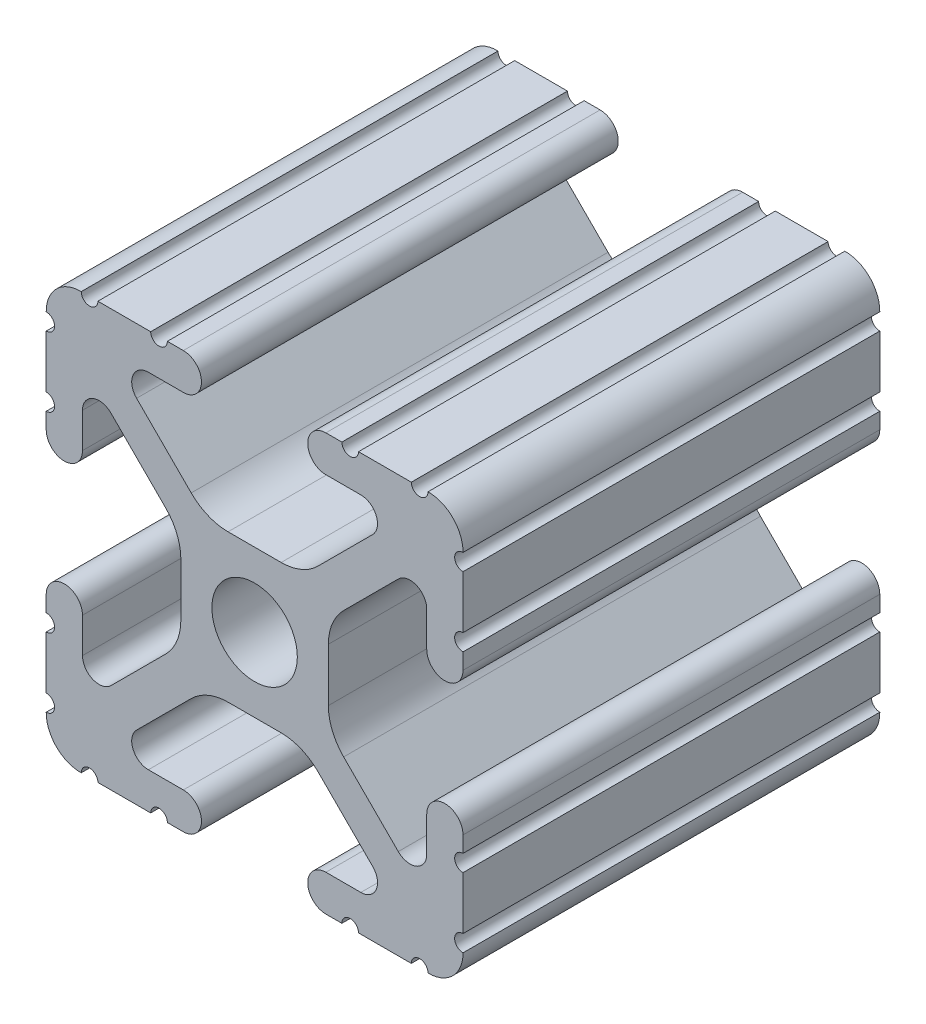
from build123d import *

# Parameters (mm, degrees)
SKETCH1_R           = 2.6035
BOSS_EXTRUDE1_DEPTH = 25.4


with BuildPart() as part:
    # Sketch1 → Boss-Extrude1 (new body)
    with BuildSketch(Plane(origin=(0, 0, -25.4), x_dir=(-1, 0, 0), z_dir=(0, 0, -1))):
        with BuildLine():
            Line((12.7, -9.5504), (12.7, -6.3330836))
            ThreePointArc((12.7, -6.3330836), (12.192, -5.8250836), (12.7, -5.3170836))
            Line((12.7, -5.3170836), (12.7, -4.3434))
            ThreePointArc((12.7, -4.3434), (11.5951, -3.2385), (10.4902, -4.3434))
            Line((10.4902, -4.3434), (10.4902, -6.474794456))
            ThreePointArc((10.4902, -6.474794456), (9.863006367, -7.413456061), (8.75577951, -7.193214945))
            Line((8.75577951, -7.193214945), (5.42573597, -3.863171405))
            ThreePointArc((5.42573597, -3.863171405), (4.737482484, -2.833127272), (4.4958, -1.618107374))
            Line((4.4958, -1.618107374), (4.4958, 1.618107374))
            ThreePointArc((4.4958, 1.618107374), (4.737482484, 2.833127272), (5.42573597, 3.863171405))
            Line((5.42573597, 3.863171405), (8.75577951, 7.193214945))
            ThreePointArc((8.75577951, 7.193214945), (9.863006367, 7.413456061), (10.4902, 6.474794456))
            Line((10.4902, 6.474794456), (10.4902, 4.343399971))
            ThreePointArc((10.4902, 4.343399971), (11.5951, 3.238499971), (12.7, 4.343399971))
            Line((12.7, 4.343399971), (12.7, 5.3170836))
            ThreePointArc((12.7, 5.3170836), (12.192, 5.8250836), (12.7, 6.3330836))
            Line((12.7, 6.3330836), (12.7, 9.5504))
            ThreePointArc((12.7, 9.5504), (12.192000006, 10.058323491), (12.699846982, 10.566399977))
            ThreePointArc((12.699846982, 10.566399977), (12.082522516, 12.082522516), (10.566399977, 12.699846982))
            ThreePointArc((10.566399977, 12.699846982), (10.058323491, 12.192000006), (9.5504, 12.7))
            Line((9.5504, 12.7), (6.3330836, 12.7))
            ThreePointArc((6.3330836, 12.7), (5.8250836, 12.192), (5.3170836, 12.7))
            Line((5.3170836, 12.7), (4.3434, 12.7))
            ThreePointArc((4.3434, 12.7), (3.2385, 11.5951), (4.3434, 10.4902))
            Line((4.3434, 10.4902), (6.474794456, 10.4902))
            ThreePointArc((6.474794456, 10.4902), (7.413456061, 9.863006367), (7.193214945, 8.75577951))
            Line((7.193214945, 8.75577951), (3.863171405, 5.42573597))
            ThreePointArc((3.863171405, 5.42573597), (2.833127272, 4.737482484), (1.618107374, 4.4958))
            Line((1.618107374, 4.4958), (-1.618107374, 4.4958))
            ThreePointArc((-1.618107374, 4.4958), (-2.833127272, 4.737482484), (-3.863171405, 5.42573597))
            Line((-3.863171405, 5.42573597), (-7.193214945, 8.75577951))
            ThreePointArc((-7.193214945, 8.75577951), (-7.413456061, 9.863006367), (-6.474794456, 10.4902))
            Line((-6.474794456, 10.4902), (-4.343399971, 10.4902))
            ThreePointArc((-4.343399971, 10.4902), (-3.238499971, 11.5951), (-4.343399971, 12.7))
            Line((-4.343399971, 12.7), (-5.3170836, 12.7))
            ThreePointArc((-5.3170836, 12.7), (-5.8250836, 12.192), (-6.3330836, 12.7))
            Line((-6.3330836, 12.7), (-9.5504, 12.7))
            ThreePointArc((-9.5504, 12.7), (-10.058323491, 12.192000006), (-10.566399977, 12.699846982))
            ThreePointArc((-10.566399977, 12.699846982), (-12.082522516, 12.082522516), (-12.699846982, 10.566399977))
            ThreePointArc((-12.699846982, 10.566399977), (-12.192000006, 10.058323491), (-12.7, 9.5504))
            Line((-12.7, 9.5504), (-12.7, 6.3330836))
            ThreePointArc((-12.7, 6.3330836), (-12.192, 5.8250836), (-12.7, 5.3170836))
            Line((-12.7, 5.3170836), (-12.7, 4.3434))
            ThreePointArc((-12.7, 4.3434), (-11.5951, 3.2385), (-10.4902, 4.3434))
            Line((-10.4902, 4.3434), (-10.4902, 6.474794456))
            ThreePointArc((-10.4902, 6.474794456), (-9.863006367, 7.413456061), (-8.75577951, 7.193214945))
            Line((-8.75577951, 7.193214945), (-5.42573597, 3.863171405))
            ThreePointArc((-5.42573597, 3.863171405), (-4.737482484, 2.833127272), (-4.4958, 1.618107374))
            Line((-4.4958, 1.618107374), (-4.4958, -1.618107374))
            ThreePointArc((-4.4958, -1.618107374), (-4.737482484, -2.833127272), (-5.42573597, -3.863171405))
            Line((-5.42573597, -3.863171405), (-8.75577951, -7.193214945))
            ThreePointArc((-8.75577951, -7.193214945), (-9.863006367, -7.413456061), (-10.4902, -6.474794456))
            Line((-10.4902, -6.474794456), (-10.4902, -4.343399971))
            ThreePointArc((-10.4902, -4.343399971), (-11.5951, -3.238499971), (-12.7, -4.343399971))
            Line((-12.7, -4.343399971), (-12.7, -5.3170836))
            ThreePointArc((-12.7, -5.3170836), (-12.192, -5.8250836), (-12.7, -6.3330836))
            Line((-12.7, -6.3330836), (-12.7, -9.5504))
            ThreePointArc((-12.7, -9.5504), (-12.192000006, -10.058323491), (-12.699846982, -10.566399977))
            ThreePointArc((-12.699846982, -10.566399977), (-12.082522516, -12.082522516), (-10.566399977, -12.699846982))
            ThreePointArc((-10.566399977, -12.699846982), (-10.058323491, -12.192000006), (-9.5504, -12.7))
            Line((-9.5504, -12.7), (-6.3330836, -12.7))
            ThreePointArc((-6.3330836, -12.7), (-5.8250836, -12.192), (-5.3170836, -12.7))
            Line((-5.3170836, -12.7), (-4.3434, -12.7))
            ThreePointArc((-4.3434, -12.7), (-3.2385, -11.5951), (-4.3434, -10.4902))
            Line((-4.3434, -10.4902), (-6.474794456, -10.4902))
            ThreePointArc((-6.474794456, -10.4902), (-7.413456061, -9.863006367), (-7.193214945, -8.75577951))
            Line((-7.193214945, -8.75577951), (-3.863171405, -5.42573597))
            ThreePointArc((-3.863171405, -5.42573597), (-2.833127272, -4.737482484), (-1.618107374, -4.4958))
            Line((-1.618107374, -4.4958), (1.618107374, -4.4958))
            ThreePointArc((1.618107374, -4.4958), (2.833127272, -4.737482484), (3.863171405, -5.42573597))
            Line((3.863171405, -5.42573597), (7.193214945, -8.75577951))
            ThreePointArc((7.193214945, -8.75577951), (7.413456061, -9.863006367), (6.474794456, -10.4902))
            Line((6.474794456, -10.4902), (4.343399971, -10.4902))
            ThreePointArc((4.343399971, -10.4902), (3.238499971, -11.5951), (4.343399971, -12.7))
            Line((4.343399971, -12.7), (5.3170836, -12.7))
            ThreePointArc((5.3170836, -12.7), (5.8250836, -12.192), (6.3330836, -12.7))
            Line((6.3330836, -12.7), (9.5504, -12.7))
            ThreePointArc((9.5504, -12.7), (10.058323491, -12.192000006), (10.566399977, -12.699846982))
            ThreePointArc((10.566399977, -12.699846982), (12.082522516, -12.082522516), (12.699846982, -10.566399977))
            ThreePointArc((12.699846982, -10.566399977), (12.192000006, -10.058323491), (12.7, -9.5504))
        make_face()
        Circle(SKETCH1_R, mode=Mode.SUBTRACT)
    extrude(amount=-BOSS_EXTRUDE1_DEPTH)


solid = part.part
